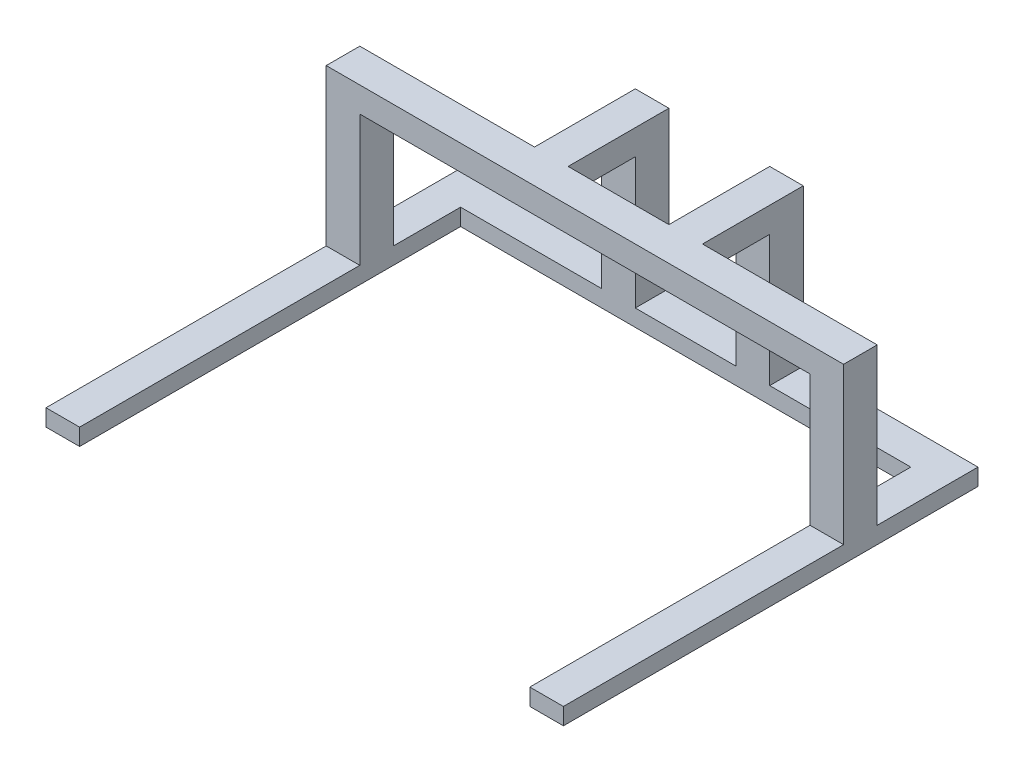
from build123d import *

# Parameters (mm, degrees)
BOSS_EXTRUDE1_DEPTH = 4.7625
SKETCH1_3_W         = 6.35
SKETCH1_3_H         = 6.35
BOSS_EXTRUDE2_DEPTH = 27.94
SKETCH2_W           = 19.05
SKETCH2_H           = 6.35
BOSS_EXTRUDE3_DEPTH = 3.175
SKETCH3_W           = 6.35
SKETCH3_H           = 52.959
BOSS_EXTRUDE4_DEPTH = 3.175


with BuildPart() as part:
    # Sketch1 → Boss-Extrude1 (new body)
    with BuildSketch(Plane(origin=(0, 0, 0), x_dir=(1, 0, 0), z_dir=(0, 1, 0))):
        Polygon((-48.895, 3.175), (-48.895, -3.175), (48.895, -3.175), (48.895, 3.175), (-9.525, 3.175), (-9.525, 22.225), (-15.875, 22.225), (-15.875, 3.175), align=None)
    extrude(amount=BOSS_EXTRUDE1_DEPTH)

    # Sketch1_3 → Boss-Extrude2 (add)
    with BuildSketch(Plane(origin=(0, 0, 0), x_dir=(1, 0, 0), z_dir=(0, 1, 0))):
        with Locations((-45.72, 0)):
            Rectangle(SKETCH1_3_W, SKETCH1_3_H)
        with Locations((45.72, 0)):
            Rectangle(SKETCH1_3_W, SKETCH1_3_H)
        with Locations((-12.7, 19.05)):
            Rectangle(SKETCH1_3_W, SKETCH1_3_H)
    extrude(amount=-BOSS_EXTRUDE2_DEPTH)

    # Mirror1: part across plane


with BuildPart() as part_1:
    add(part.part)
    add(part.part.mirror(Plane(origin=(0, 0, 0), x_dir=(0, 0, 1), z_dir=(1, 0, 0))))

    # Sketch2 → Boss-Extrude3 (add)
    with BuildSketch(Plane.XZ.offset(27.94)):
        with Locations((0, -19.05)):
            Rectangle(SKETCH2_W, SKETCH2_H)
        Polygon((-42.545, 3.175), (-48.895, 3.175), (-48.895, -22.225), (-15.875, -22.225), (-15.875, -15.875), (-42.545, -15.875), align=None)
        Polygon((48.895, 3.175), (42.545, 3.175), (42.545, -15.875), (15.875, -15.875), (15.875, -22.225), (48.895, -22.225), align=None)
    extrude(amount=-BOSS_EXTRUDE3_DEPTH)

    # Sketch3 → Boss-Extrude4 (add)
    with BuildSketch(Plane.XZ.offset(27.94)):
        with Locations((-45.72, 29.6545)):
            Rectangle(SKETCH3_W, SKETCH3_H)
    boss_extrude4 = extrude(amount=-BOSS_EXTRUDE4_DEPTH)

    # Mirror2: Boss-Extrude4 across plane
    add(boss_extrude4.mirror(Plane(origin=(0, 0, 0), x_dir=(0, 0, 1), z_dir=(1, 0, 0))))


solid = part_1.part
